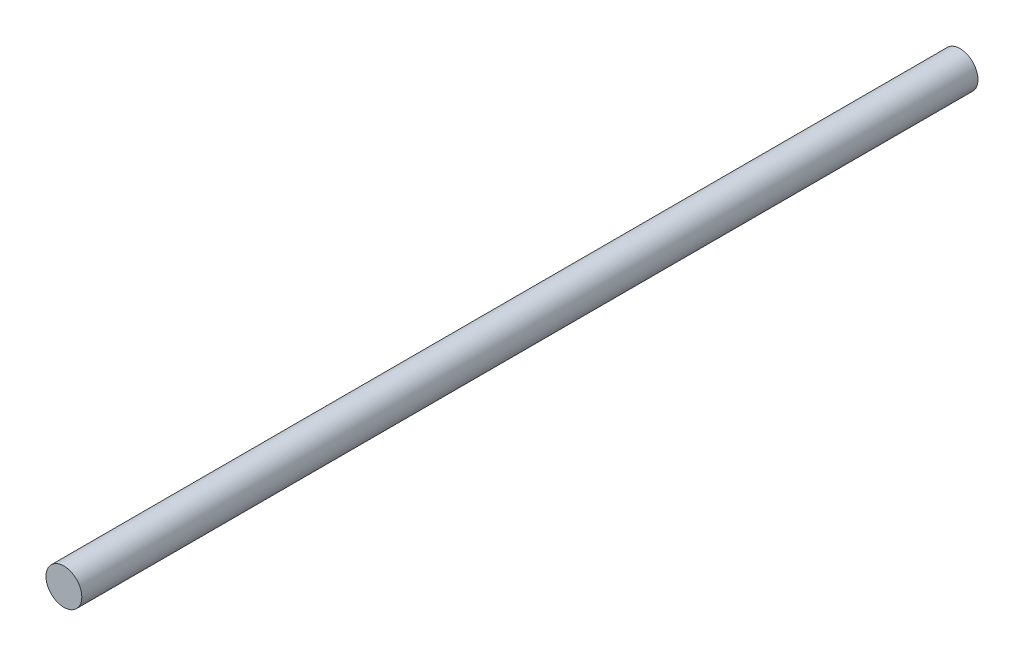
from build123d import *

# Parameters (mm, degrees)
SKETCH1_R           = 10
BOSS_EXTRUDE1_DEPTH = 250


with BuildPart() as part:
    # Sketch1 → Boss-Extrude1 (new body, symmetric)
    with BuildSketch(Plane.XY):
        Circle(SKETCH1_R)
    extrude(amount=BOSS_EXTRUDE1_DEPTH, both=True)


solid = part.part
